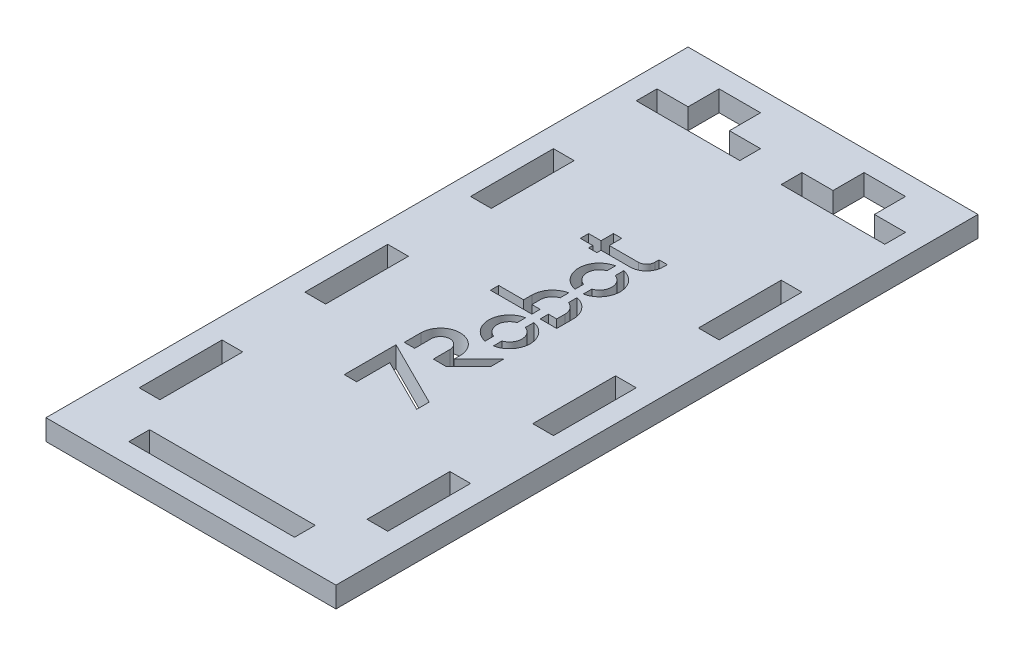
from build123d import *

# Parameters (mm, degrees)
ESQUISSE1_W             = 70
ESQUISSE1_H             = 155
ESQUISSE1_W_2           = 5
ESQUISSE1_H_2           = 20
ESQUISSE1_W_3           = 40
ESQUISSE1_H_3           = 5
BOSS_EXTRU_1_DEPTH      = 5
ENL_V_MAT_EXTRU_1_DEPTH = 5


with BuildPart() as part:
    # Esquisse1 → Boss.-Extru.1 (new body)
    with BuildSketch(Plane(origin=(0, 0, 0), x_dir=(1, 0, 0), z_dir=(0, 1, 0))):
        with Locations((0, 5)):
            Rectangle(ESQUISSE1_W, ESQUISSE1_H)
        Polygon((-22.5, 77.5), (-12.5, 77.5), (-12.5, 70), (-5, 70), (-5, 65), (-30, 65), (-30, 70), (-22.5, 70), align=None, mode=Mode.SUBTRACT)
        with Locations((27.5, 35)):
            Rectangle(ESQUISSE1_W_2, ESQUISSE1_H_2, mode=Mode.SUBTRACT)
        with Locations((-27.5, 35)):
            Rectangle(ESQUISSE1_W_2, ESQUISSE1_H_2, mode=Mode.SUBTRACT)
        Polygon((12.5, 77.5), (22.5, 77.5), (22.5, 70), (30, 70), (30, 65), (5, 65), (5, 70), (12.5, 70), align=None, mode=Mode.SUBTRACT)
        with Locations((-27.5, -5)):
            Rectangle(ESQUISSE1_W_2, ESQUISSE1_H_2, mode=Mode.SUBTRACT)
        with Locations((-27.5, -45)):
            Rectangle(ESQUISSE1_W_2, ESQUISSE1_H_2, mode=Mode.SUBTRACT)
        with Locations((27.5, -5)):
            Rectangle(ESQUISSE1_W_2, ESQUISSE1_H_2, mode=Mode.SUBTRACT)
        with Locations((27.5, -45)):
            Rectangle(ESQUISSE1_W_2, ESQUISSE1_H_2, mode=Mode.SUBTRACT)
        with Locations((0, -65)):
            Rectangle(ESQUISSE1_W_3, ESQUISSE1_H_3, mode=Mode.SUBTRACT)
    extrude(amount=BOSS_EXTRU_1_DEPTH)

    # Esquisse2 → Enlèv. mat.-Extru.1 (cut)
    with BuildSketch(Plane(origin=(0, 5, 0), x_dir=(1, 0, 0), z_dir=(0, 1, 0))):
        Polygon((-8, -27.5), (-5, -27.5), (-5, -19.5), (8, -26), (8, -23), (-8, -15), align=None)
        with BuildLine():
            Line((8, -5), (8, -8))
            Line((8, -8), (2.5, -13.5))
            Line((2.5, -13.5), (-0.5, -13.5))
            Line((-0.5, -13.5), (-0.5, -9.5))
            ThreePointArc((-0.5, -9.5), (-2.75, -7.25), (-5, -9.5))
            Line((-5, -9.5), (-5, -13.5))
            Line((-5, -13.5), (-7.5, -13.5))
            Line((-7.5, -13.5), (-7.5, -9.5))
            ThreePointArc((-7.5, -9.5), (-2.75, -4.75), (2, -9.5))
            Line((2, -9.5), (2, -11))
            Line((2, -11), (8, -5))
        make_face()
        with BuildLine():
            Line((2, -3.5), (2, -1.429447639))
            ThreePointArc((2, -1.429447639), (0, 1.398979486), (2, 4.22740661))
            Line((2, 4.22740661), (2, 6.297958971))
            ThreePointArc((2, 6.297958971), (-2, 1.398979486), (2, -3.5))
        make_face()
        with BuildLine():
            Line((4, 6.297958971), (4, 4.22740661))
            ThreePointArc((4, 4.22740661), (6, 1.398979486), (4, -1.429447639))
            Line((4, -1.429447639), (4, -3.5))
            ThreePointArc((4, -3.5), (8, 1.398979486), (4, 6.297958971))
        make_face()
        with BuildLine():
            Line((-8, 7.797958971), (2, 7.797958971))
            Line((2, 7.797958971), (2, 9.797958971))
            Line((2, 9.797958971), (0, 9.797958971))
            Line((0, 9.797958971), (0, 11.797958971))
            ThreePointArc((0, 11.797958971), (0.550510257, 13.530009779), (2, 14.626386096))
            Line((2, 14.626386096), (2, 16.696938457))
            ThreePointArc((2, 16.696938457), (-0.872983346, 14.960236631), (-2, 11.797958971))
            Line((-2, 11.797958971), (-2, 9.797958971))
            Line((-2, 9.797958971), (-8, 9.797958971))
            Line((-8, 9.797958971), (-8, 7.797958971))
        make_face()
        with BuildLine():
            Line((4, 7.797958971), (8, 7.797958971))
            Line((8, 7.797958971), (8, 11.797958971))
            ThreePointArc((8, 11.797958971), (6.872983346, 14.960236631), (4, 16.696938457))
            Line((4, 16.696938457), (4, 14.626386096))
            ThreePointArc((4, 14.626386096), (5.449489743, 13.530009779), (6, 11.797958971))
            Line((6, 11.797958971), (6, 9.797958971))
            Line((6, 9.797958971), (4, 9.797958971))
            Line((4, 9.797958971), (4, 7.797958971))
        make_face()
        with BuildLine():
            Line((2, 18.196938457), (2, 20.267490818))
            ThreePointArc((2, 20.267490818), (0, 23.095917942), (2, 25.924345067))
            Line((2, 25.924345067), (2, 27.994897428))
            ThreePointArc((2, 27.994897428), (-2, 23.095917942), (2, 18.196938457))
        make_face()
        with BuildLine():
            Line((4, 27.994897428), (4, 25.924345067))
            ThreePointArc((4, 25.924345067), (6, 23.095917942), (4, 20.267490818))
            Line((4, 20.267490818), (4, 18.196938457))
            ThreePointArc((4, 18.196938457), (8, 23.095917942), (4, 27.994897428))
        make_face()
        with BuildLine():
            Line((-8, 29.494897428), (-5, 29.494897428))
            Line((-5, 29.494897428), (-5, 28.494897428))
            Line((-5, 28.494897428), (-3, 28.494897428))
            Line((-3, 28.494897428), (-3, 29.494897428))
            Line((-3, 29.494897428), (4, 29.494897428))
            ThreePointArc((4, 29.494897428), (6.828427125, 30.666470303), (8, 33.494897428))
            Line((8, 33.494897428), (8, 34.494897428))
            Line((8, 34.494897428), (6, 34.494897428))
            Line((6, 34.494897428), (6, 33.494897428))
            ThreePointArc((6, 33.494897428), (5.414213562, 32.080683865), (4, 31.494897428))
            Line((4, 31.494897428), (-3, 31.494897428))
            Line((-3, 31.494897428), (-3, 34.494897428))
            Line((-3, 34.494897428), (-5, 34.494897428))
            Line((-5, 34.494897428), (-5, 31.494897428))
            Line((-5, 31.494897428), (-8, 31.494897428))
            Line((-8, 31.494897428), (-8, 29.494897428))
        make_face()
    extrude(amount=-ENL_V_MAT_EXTRU_1_DEPTH, mode=Mode.SUBTRACT)


solid = part.part
